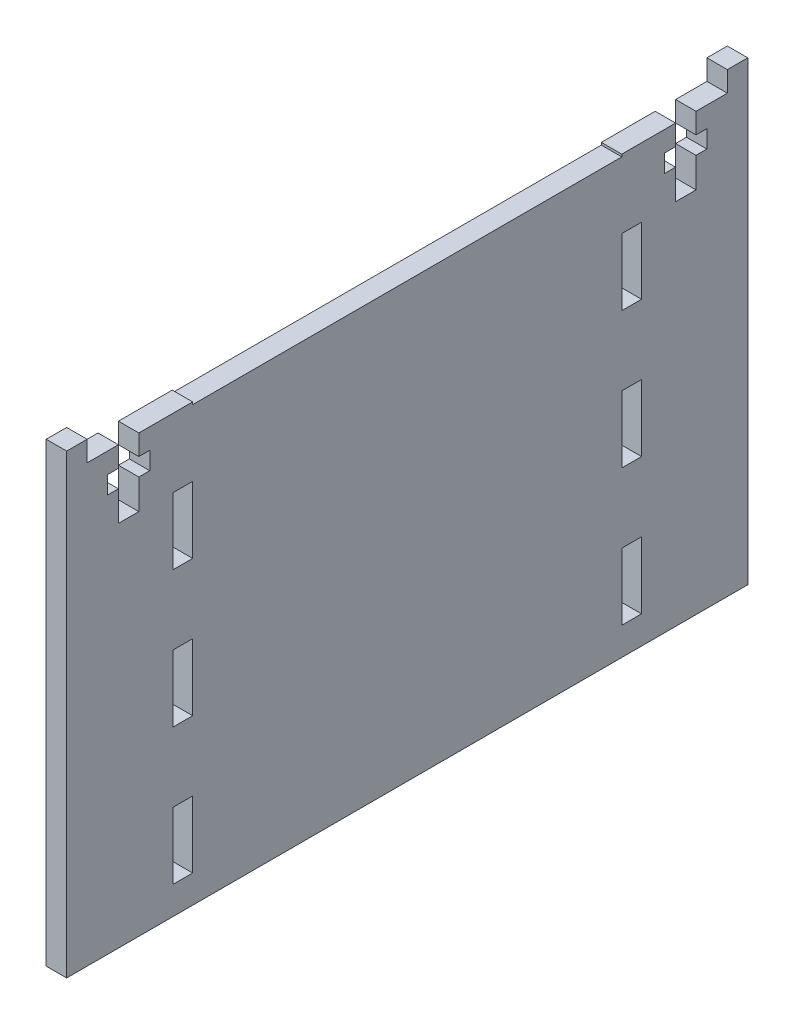
from build123d import *

# Parameters (mm, degrees)
SKETCH1_W           = 100
SKETCH1_H           = 64
BOSS_EXTRUDE1_DEPTH = 3
SKETCH2_W           = 2.9
SKETCH2_H           = 9.8
CUT_EXTRUDE1_DEPTH  = 3
CUT_EXTRUDE2_DEPTH  = 10
SKETCH5_W           = 63
SKETCH5_H           = 0.35
CUT_EXTRUDE3_DEPTH  = 10
SKETCH6_W           = 3
SKETCH6_H           = 3
BOSS_EXTRUDE3_DEPTH = 3


with BuildPart() as part:
    # Sketch1 → Boss-Extrude1 (new body)
    with BuildSketch(Plane(origin=(0, 0, 0), x_dir=(0, 0, -1), z_dir=(1, 0, 0))):
        Rectangle(SKETCH1_W, SKETCH1_H)
    extrude(amount=BOSS_EXTRUDE1_DEPTH)

    # Sketch2 → Cut-Extrude1 (cut)
    with BuildSketch(Plane(origin=(3, 0, 0), x_dir=(0, 0, -1), z_dir=(1, 0, 0))):
        with Locations((-32.95, 17)):
            Rectangle(SKETCH2_W, SKETCH2_H)
        with Locations((-32.95, -3)):
            Rectangle(SKETCH2_W, SKETCH2_H)
        with Locations((-32.95, -23)):
            Rectangle(SKETCH2_W, SKETCH2_H)
        with Locations((32.95, -23)):
            Rectangle(SKETCH2_W, SKETCH2_H)
        with Locations((32.95, -3)):
            Rectangle(SKETCH2_W, SKETCH2_H)
        with Locations((32.95, 17)):
            Rectangle(SKETCH2_W, SKETCH2_H)
    extrude(amount=-CUT_EXTRUDE1_DEPTH, mode=Mode.SUBTRACT)

    # Sketch3 → Cut-Extrude2 (cut)
    with BuildSketch(Plane(origin=(3, 0, 0), x_dir=(0, 0, -1), z_dir=(1, 0, 0))):
        Polygon((-42.4, 32), (-42.4, 29), (-44, 29), (-44, 26.4), (-42.4, 26.4), (-42.4, 22), (-39.4, 22), (-39.4, 26.4), (-37.8, 26.4), (-37.8, 29), (-39.4, 29), (-39.4, 32), align=None)
    cut_extrude2 = extrude(amount=-CUT_EXTRUDE2_DEPTH, mode=Mode.SUBTRACT)

    # Mirror1: Cut-Extrude2 across plane
    add(cut_extrude2.mirror(Plane.XY), mode=Mode.SUBTRACT)

    # Sketch5 → Cut-Extrude3 (cut)
    with BuildSketch(Plane(origin=(3, 0, 0), x_dir=(0, 0, -1), z_dir=(1, 0, 0))):
        with Locations((0, 31.825)):
            Rectangle(SKETCH5_W, SKETCH5_H)
    extrude(amount=-CUT_EXTRUDE3_DEPTH, mode=Mode.SUBTRACT)

    # Sketch6 → Boss-Extrude3 (add)
    with BuildSketch(Plane.ZY):
        with Locations((-48.5, 33.5)):
            Rectangle(SKETCH6_W, SKETCH6_H)
        with Locations((48.5, 33.5)):
            Rectangle(SKETCH6_W, SKETCH6_H)
    extrude(amount=-BOSS_EXTRUDE3_DEPTH)


solid = part.part
